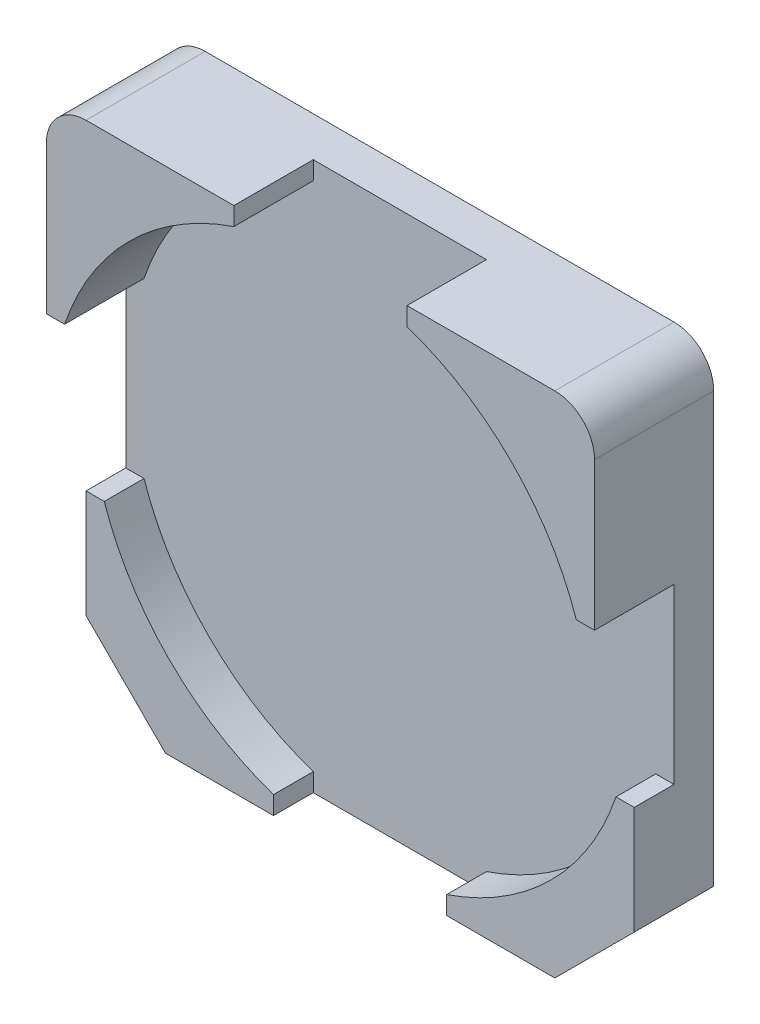
from build123d import *

# Parameters (mm, degrees)
ESQUISSE1_W             = 6.9
ESQUISSE1_H             = 6.9
BOSS_EXTRU_1_DEPTH      = 1.5
ESQUISSE2_R             = 3.4
ENL_V_MAT_EXTRU_7_DEPTH = 1
ENL_V_MAT_EXTRU_8_DEPTH = 1
ESQUISSE4_W             = 6.9
ESQUISSE4_H             = 2.359638985
ENL_V_MAT_EXTRU_9_DEPTH = 0.5
CHANFREIN1_SIZE         = 1
CONG_1_R                = 0.5


with BuildPart() as part:
    # Esquisse1 → Boss.-Extru.1 (new body)
    with BuildSketch(Plane.XY):
        with Locations((3.45, 3.45)):
            Rectangle(ESQUISSE1_W, ESQUISSE1_H)
    extrude(amount=BOSS_EXTRU_1_DEPTH)

    # Esquisse2 → Enlèv. mat.-Extru.7 (cut)
    with BuildSketch(Plane.XY.offset(1.5)):
        with Locations((3.45, 3.45)):
            Circle(ESQUISSE2_R)
    extrude(amount=-ENL_V_MAT_EXTRU_7_DEPTH, mode=Mode.SUBTRACT)

    # Esquisse3 → Enlèv. mat.-Extru.8 (cut)
    with BuildSketch(Plane.XY.offset(1.5)):
        Polygon((0, 4.540361015), (2.36, 4.540361015), (2.36, 6.9), (4.54, 6.9), (4.54, 4.540361015), (6.9, 4.540361015), (6.9, 2.359638985), (4.54, 2.359638985), (4.54, 0), (2.36, 0), (2.36, 2.359638985), (0, 2.359638985), align=None)
    extrude(amount=-ENL_V_MAT_EXTRU_8_DEPTH, mode=Mode.SUBTRACT)

    # Esquisse4 → Enlèv. mat.-Extru.9 (cut)
    with BuildSketch(Plane.XY.offset(1.5)):
        with Locations((3.45, 1.179819493)):
            Rectangle(ESQUISSE4_W, ESQUISSE4_H)
    extrude(amount=-ENL_V_MAT_EXTRU_9_DEPTH, mode=Mode.SUBTRACT)

    # Chanfrein1
    chanfrein1_edges = [part.edges().sort_by_distance(p)[0] for p in [
        (6.9, 0, 0.5),
        (0, 0, 0.5),
    ]]
    chamfer(chanfrein1_edges, length=CHANFREIN1_SIZE)

    # Congé1
    cong_1_edges = [part.edges().sort_by_distance(p)[0] for p in [
        (0, 6.9, 0.75),
        (6.9, 6.9, 0.75),
    ]]
    fillet(cong_1_edges, radius=CONG_1_R)


solid = part.part
